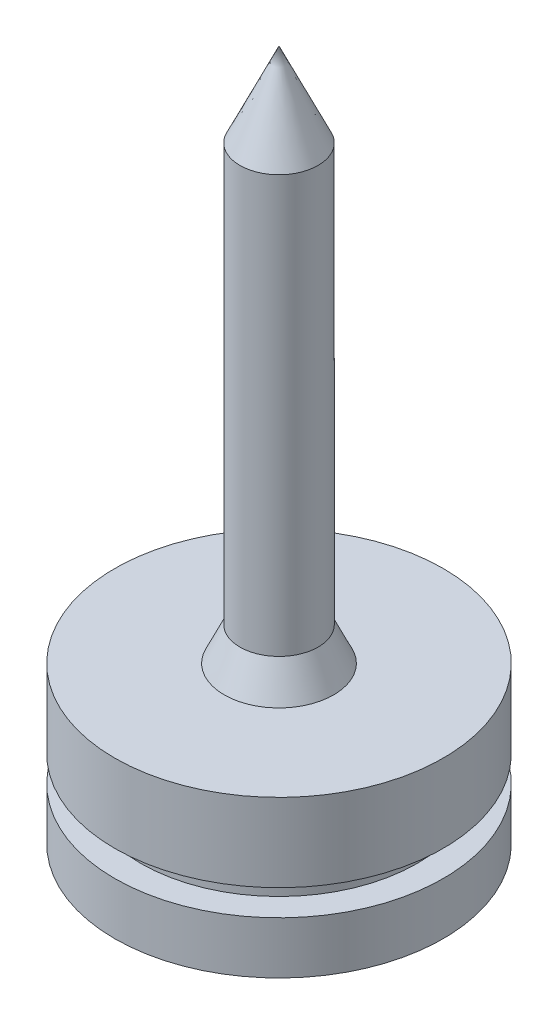
from build123d import *


with BuildPart() as part:
    # 草图3 → 旋转1 (revolve)
    with BuildSketch(Plane(origin=(0, 0, 0), x_dir=(0, 0, -1), z_dir=(1, 0, 0))):
        Polygon((0, 0), (-31.5, 0), (-31.5, 10), (-26.5, 10), (-26.5, 15), (-31.5, 15), (-31.5, 30), (-10.5, 30), (-7.5, 36.433520762), (-7.5, 116.433520762), (0, 132.517322665), align=None)
    revolve(axis=Axis((0, 132.517322665, 0), (0, -1, 0)))


solid = part.part
